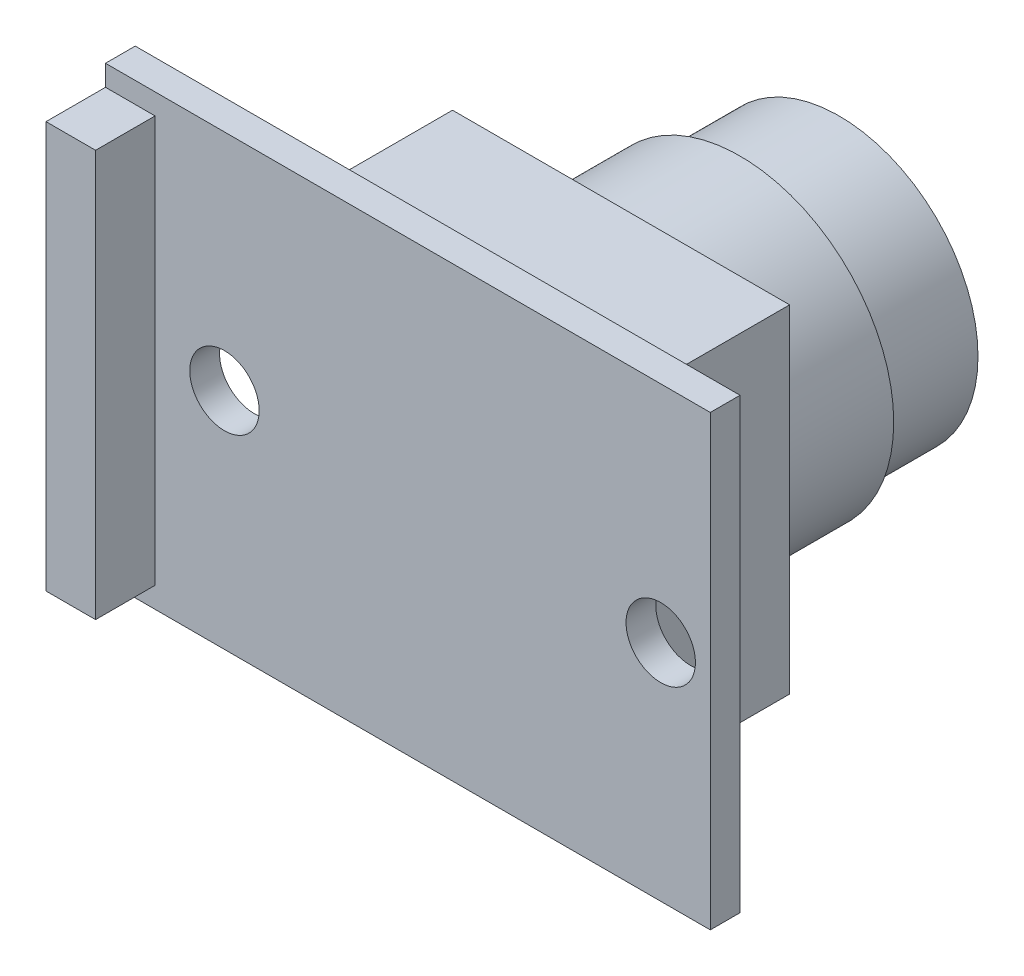
from build123d import *

# Parameters (mm, degrees)
SKETCH_1_R      = 7
EXTRUDE_1_DEPTH = 5
SKETCH_2_R      = 7.75
EXTRUDE_2_DEPTH = 6
SKETCH_3_W      = 17
SKETCH_3_H      = 17
EXTRUDE_3_DEPTH = 8
SKETCH_4_W      = 30.5
SKETCH_4_H      = 22.6
SKETCH_4_R      = 1.75
EXTRUDE_4_DEPTH = 1.5
SKETCH_5_W      = 2.5
SKETCH_5_H      = 20.5
EXTRUDE_5_DEPTH = 3


with BuildPart() as part:
    # 草图1 → 凸台-拉伸1 (new body)
    with BuildSketch(Plane.XY):
        Circle(SKETCH_1_R)
    extrude(amount=EXTRUDE_1_DEPTH)

    # 草图2 → 凸台-拉伸2 (add)
    with BuildSketch(Plane.XY.offset(5)):
        Circle(SKETCH_2_R)
    extrude(amount=EXTRUDE_2_DEPTH)

    # 草图3 → 凸台-拉伸3 (add)
    with BuildSketch(Plane.XY.offset(11)):
        Rectangle(SKETCH_3_W, SKETCH_3_H)
    extrude(amount=EXTRUDE_3_DEPTH)

    # 草图4 → 凸台-拉伸4 (add)
    with BuildSketch(Plane.XY.offset(19)):
        with Locations((-1.25, 0)):
            Rectangle(SKETCH_4_W, SKETCH_4_H)
        with Locations((11.5, 0)):
            Circle(SKETCH_4_R, mode=Mode.SUBTRACT)
        with Locations((-10.5, 0)):
            Circle(SKETCH_4_R, mode=Mode.SUBTRACT)
    extrude(amount=EXTRUDE_4_DEPTH)

    # 草图5 → 凸台-拉伸5 (add)
    with BuildSketch(Plane.XY.offset(20.5)):
        with Locations((-15.25, 0)):
            Rectangle(SKETCH_5_W, SKETCH_5_H)
    extrude(amount=EXTRUDE_5_DEPTH)


solid = part.part
